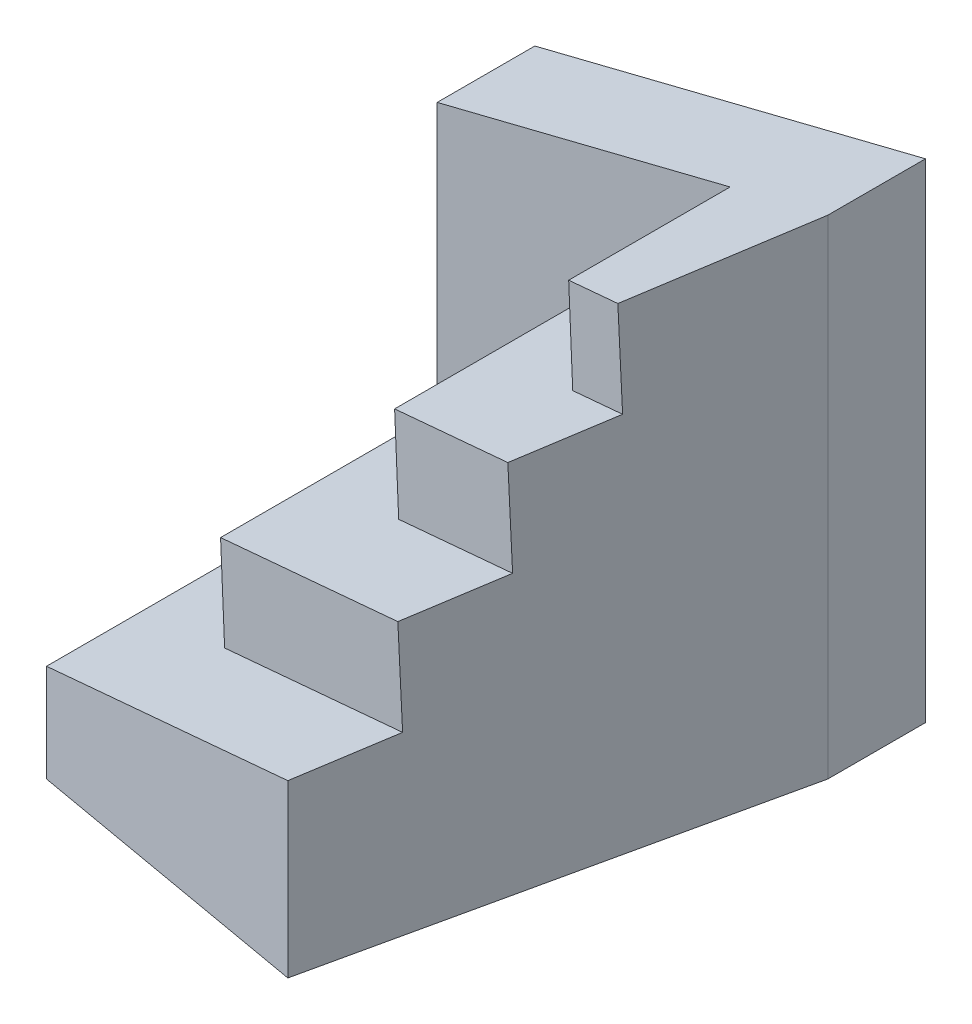
from build123d import *

# Parameters (mm, degrees)
MAIN_BLOCK_DEPTH         = 90
MAIN_CUTOUT_DEPTH        = 10
MAIN_CUTOUT_DEPTH_BACK   = 72
TOP_SLOPE_CUT_DEPTH      = 12
TOP_SLOPE_CUT_DEPTH_BACK = 90
FIRST_STEP_CUT_DEPTH     = 90
SECOND_STEP_CUT_DEPTH    = 50
THIRD_STEP_CUT_DEPTH     = 20


with BuildPart() as part:
    # Sketch1 → Main Block (new body)
    with BuildSketch(Plane(origin=(0, 0, 0), x_dir=(1, 0, 0), z_dir=(0, 1, 0))):
        Polygon((0, 0), (0, 90), (72, 90), (72, 72), (54, -9.521656958), align=None)
    extrude(amount=MAIN_BLOCK_DEPTH)

    # Sketch4 → Main Cutout (cut, two sides)
    with BuildSketch(Plane.XY) as main_cutout_sk:
        Polygon((18, 40.5), (18, 22.5), (0, 18), (0, 90), (54, 90), (54, 67.5), (36, 63), (36, 45), align=None)
    extrude(amount=MAIN_CUTOUT_DEPTH, mode=Mode.SUBTRACT)
    extrude(main_cutout_sk.sketch, amount=-MAIN_CUTOUT_DEPTH_BACK, mode=Mode.SUBTRACT)

    # Sketch5 → Top Slope Cut (cut, two sides)
    with BuildSketch(Plane.XY) as top_slope_cut_sk:
        Polygon((0, 90), (72, 90), (0, 72), align=None)
    extrude(amount=TOP_SLOPE_CUT_DEPTH, mode=Mode.SUBTRACT)
    extrude(top_slope_cut_sk.sketch, amount=-TOP_SLOPE_CUT_DEPTH_BACK, mode=Mode.SUBTRACT)

    # Sketch6 → First Step Cut (cut)
    with BuildSketch(Plane(origin=(-4.235294118, 16.941176471, 0), x_dir=(-0.9701425, -0.242535625, 0), z_dir=(-0.242535625, 0.9701425, 0))):
        Polygon((-92.892158272, -2.856450573), (-85.203658571, 13.828337001), (-4.365641251, 0), (-4.365641251, -18), align=None)
    extrude(amount=FIRST_STEP_CUT_DEPTH, mode=Mode.SUBTRACT)

    # Sketch7 → Second Step Cut (cut)
    with BuildSketch(Plane(origin=(-8.470588235, 33.882352941, 0), x_dir=(-0.9701425, -0.242535625, 0), z_dir=(-0.242535625, 0.9701425, 0))):
        Polygon((-27.285257817, -14.079317723), (-101.742779454, -1.342442975), (-101.770582014, -19.337687006), (-27.285257817, -32.079317723), align=None)
    extrude(amount=SECOND_STEP_CUT_DEPTH, mode=Mode.SUBTRACT)

    # Sketch8 → Third Step Cut (cut)
    with BuildSketch(Plane(origin=(-12.705882353, 50.823529412, 0), x_dir=(-0.9701425, -0.242535625, 0), z_dir=(-0.242535625, 0.9701425, 0))):
        Polygon((-50.204874383, -28.158635446), (-102.913338561, -19.142204445), (-106.827474424, -36.47264337), (-50.204874383, -46.158635446), align=None)
    extrude(amount=THIRD_STEP_CUT_DEPTH, mode=Mode.SUBTRACT)


solid = part.part
